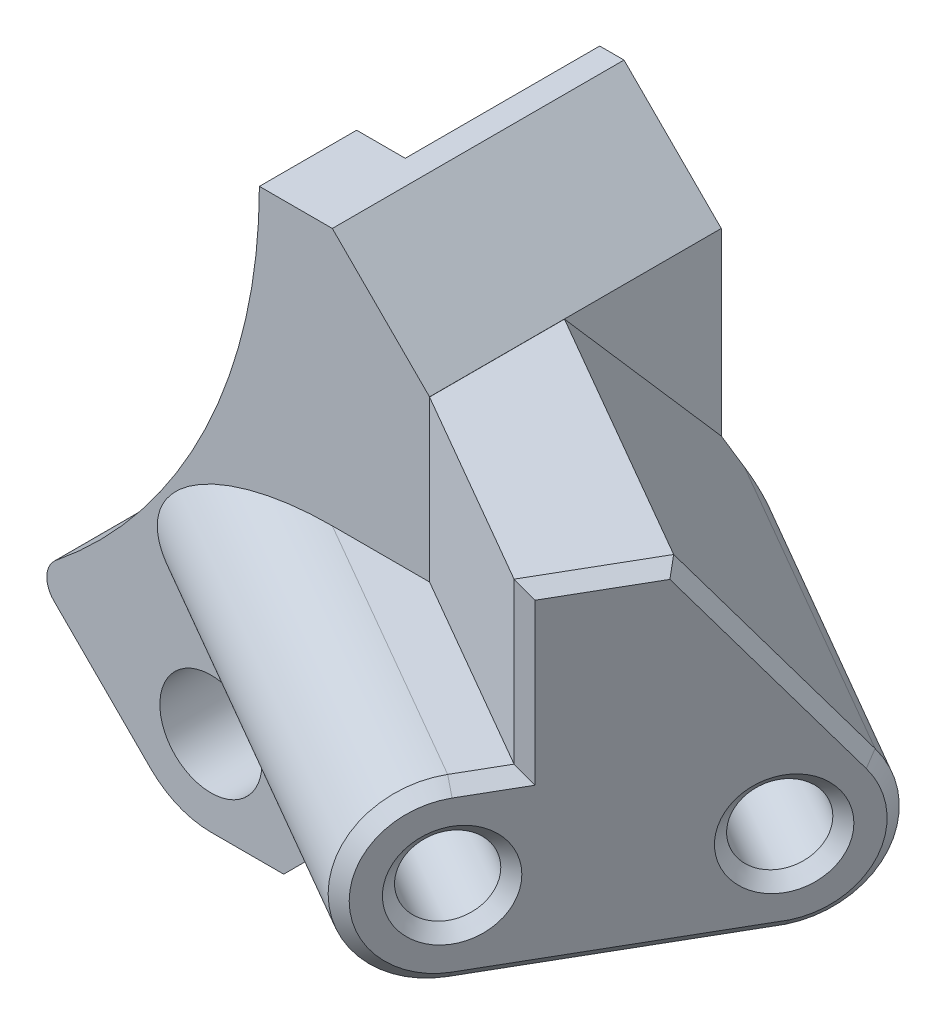
from build123d import *

# Parameters (mm, degrees)
SKETCH1_R           = 2.100000000000001
BOSS_EXTRUDE1_DEPTH = 12
BOSS_EXTRUDE2_START = -6.21
BOSS_EXTRUDE2_DEPTH = 13.79
CUT_EXTRUDE1_DEPTH  = 8
BOSS_EXTRUDE3_REACH = 41.051
SKETCH4_R           = 1.6
SKETCH4_R_2         = 1.6000000000000019
CUT_EXTRUDE2_DEPTH  = 40.05068839257359
CHAMFER2_SIZE       = 4
CUT_EXTRUDE3_REACH  = 41.051
CHAMFER3_SIZE       = 6
CUT_EXTRUDE4_START  = -12.5
CUT_EXTRUDE4_DEPTH  = 27.550688504002913
FILLET1_R           = 1
CHAMFER4_SIZE       = 0.5
FILLET2_R           = 3


with BuildPart() as part:
    # Sketch1 → Boss-Extrude1 (new body)
    with BuildSketch(Plane.XY):
        with BuildLine():
            Line((13.241359911348773, -18.191107379654646), (18.031222920256923, -22.980970388562806))
            ThreePointArc((18.031222920256923, -22.980970388562806), (19.166704641132032, -23.73967501819941), (20.50609665440986, -24.006096654409898))
            Line((20.50609665440986, -24.006096654409898), (29.499999999999993, -24.006096654409898))
            Line((29.499999999999993, -24.006096654409898), (29.499999999999993, 3.7e-16))
            Line((29.499999999999993, 3.7e-16), (22.500000000000007, 1.32e-15))
            ThreePointArc((22.500000000000007, 1.32e-15), (20.052189381777588, -10.205866009179541), (13.241359911348773, -18.191107379654646))
        make_face()
        with Locations((20.506096654409866, -20.5060966544099)):
            Circle(SKETCH1_R, mode=Mode.SUBTRACT)
    extrude(amount=BOSS_EXTRUDE1_DEPTH)

    # Sketch2 → Boss-Extrude2 (add)
    with BuildSketch(Plane.XZ.offset(24.006096654409898).offset(BOSS_EXTRUDE2_START)):
        Polygon((36.42820323027541, 1.1e-16), (29.499999999999993, 0), (29.499999999999993, 12), (38.1602540378444, 16.99999999999995), (45.08845726811982, 4.999999999999951), align=None)
    extrude(amount=-BOSS_EXTRUDE2_DEPTH)

    # Sketch3 → Cut-Extrude1 (cut)
    with BuildSketch(Plane(origin=(0, 0, 0), x_dir=(-1, 0, 0), z_dir=(0, 0, -1))):
        with BuildLine():
            Line((-18.031222920256923, -22.980970388562806), (-14.671554465329313, -19.621301933635188))
            ThreePointArc((-14.671554465329313, -19.621301933635188), (17.324116139070405, 17.324116139070437), (-19.621301933635156, -14.671554465329354))
            Line((-19.621301933635156, -14.671554465329354), (-22.98097038856278, -18.031222920256983))
            ThreePointArc((-22.98097038856278, -18.031222920256983), (-23.739675018199375, -19.1667046411321), (-24.00609665440987, -20.506096654409927))
            Line((-24.00609665440987, -20.506096654409927), (-24.00609665440987, -24.0060966544099))
            Line((-24.00609665440987, -24.0060966544099), (-20.50609665440986, -24.006096654409905))
            ThreePointArc((-20.50609665440986, -24.006096654409905), (-19.166704641132036, -23.739675018199403), (-18.031222920256923, -22.980970388562806))
        make_face()
    extrude(amount=-CUT_EXTRUDE1_DEPTH, mode=Mode.SUBTRACT)

    # Boss-Extrude3: up to this plane
    boss_extrude3_end = Plane(origin=(0, 0, 12), z_dir=(0, 0, 1))
    # Sketch5 → Boss-Extrude3 (add, up to the surface)
    with BuildSketch(Plane(origin=(35.98140646055117, 0, 20.77387470582027), x_dir=(0.4999999999999946, 0, -0.8660254037844417), z_dir=(0.8660254037844417, 0, 0.4999999999999946)), mode=Mode.PRIVATE) as boss_extrude3_sk1:
        with BuildLine():
            Line((2.357695154586543, -10.5960966544099), (4.357695154586543, -10.5960966544099))
            Line((4.357695154586543, -10.5960966544099), (4.357695154586545, -17.796096654409897))
            Line((4.357695154586545, -17.796096654409897), (2.3576951545865437, -17.796096654409897))
            ThreePointArc((2.3576951545865437, -17.796096654409897), (-1.2423048454134564, -14.1960966544099), (2.357695154586543, -10.5960966544099))
        make_face()
    boss_extrude3_tool1 = split(extrude(boss_extrude3_sk1.sketch, amount=-BOSS_EXTRUDE3_REACH, mode=Mode.PRIVATE), bisect_by=boss_extrude3_end, keep=Keep.BOTH, mode=Mode.PRIVATE)
    add(boss_extrude3_tool1.solids().sort_by_distance((36.919961, -14.196097, 19.148251))[0])

    # Sketch4 → Cut-Extrude2 (cut, through all)
    with BuildSketch(Plane(origin=(35.98140646055118, 0, 20.773874705820273), x_dir=(0.49999999999999495, 0, -0.8660254037844417), z_dir=(0.8660254037844417, 0, 0.49999999999999495))):
        with Locations((2.357695154586536, -14.2)):
            Circle(SKETCH4_R)
        with Locations((12.357695154586537, -14.2)):
            Circle(SKETCH4_R_2)
    extrude(amount=-CUT_EXTRUDE2_DEPTH, mode=Mode.SUBTRACT)

    # Chamfer2
    chamfer2_edges = [part.edges().sort_by_distance(p)[0] for p in [
        (29.499999999999993, 3.7e-16, 6),
    ]]
    chamfer(chamfer2_edges, length=CHAMFER2_SIZE)

    # Cut-Extrude3: up to this plane
    cut_extrude3_end = Plane(origin=(29.499999999999993, -24.006096654409898, 12), z_dir=(-1, 0, 0))
    # Sketch7 → Cut-Extrude3 (cut, up to the surface)
    with BuildSketch(Plane(origin=(35.98140646055117, 0, 20.77387470582027), x_dir=(0.4999999999999946, 0, -0.8660254037844417), z_dir=(0.8660254037844417, 0, 0.4999999999999946)), mode=Mode.PRIVATE) as cut_extrude3_sk1:
        with BuildLine():
            Line((15.22937626137959, -12.028952413951306), (9.16393898536506, -4.0060966544099))
            Line((9.16393898536506, -4.0060966544099), (22.041886428240783, -4.0060966544099))
            Line((22.041886428240783, -4.0060966544099), (22.041886428240783, -24.0060966544099))
            Line((22.041886428240783, -24.0060966544099), (2.357695154586543, -24.006096654409905))
            Line((2.357695154586543, -24.006096654409905), (2.357695154586542, -17.796096654409897))
            Line((2.357695154586542, -17.796096654409897), (12.357695154586544, -17.8))
            ThreePointArc((12.357695154586544, -17.8), (15.580719457145811, -15.803781264734175), (15.22937626137959, -12.028952413951306))
        make_face()
    cut_extrude3_tool1 = split(extrude(cut_extrude3_sk1.sketch, amount=-CUT_EXTRUDE3_REACH, mode=Mode.PRIVATE), bisect_by=cut_extrude3_end, keep=Keep.BOTH, mode=Mode.PRIVATE)
    add(cut_extrude3_tool1.solids().sort_by_distance((42.191658, -7.848292, 10.017403))[0], mode=Mode.SUBTRACT)

    # Chamfer3
    chamfer3_edges = [part.edges().sort_by_distance(p)[0] for p in [
        (29.499999999999993, -24.006096654409898, 6),
    ]]
    chamfer(chamfer3_edges, length=CHAMFER3_SIZE)

    # Sketch8 → Cut-Extrude4 (cut, through all)
    with BuildSketch(Plane(origin=(35.98140646055117, 0, 20.77387470582027), x_dir=(0.4999999999999946, 0, -0.8660254037844417), z_dir=(0.8660254037844417, 0, 0.4999999999999946)).offset(CUT_EXTRUDE4_START)):
        Polygon((5.257695154586542, -15.874315780649912), (5.257695154586541, -12.525684219350083), (2.3576951545865397, -10.85136843870017), (-0.5423048454134567, -12.525684219350083), (-0.5423048454134562, -15.874315780649912), (2.3576951545865446, -17.54863156129983), align=None)
        Polygon((9.457695154586544, -12.525684219350088), (9.457695154586544, -15.874315780649908), (12.35769515458654, -17.54863156129982), (15.257695154586537, -15.874315780649905), (15.257695154586537, -12.525684219350087), (12.357695154586539, -10.851368438700176), align=None)
    extrude(amount=-CUT_EXTRUDE4_DEPTH, mode=Mode.SUBTRACT)

    # Fillet1
    fillet1_edges = [part.edges().sort_by_distance(p)[0] for p in [
        (13.241359911348777, -18.191107379654646, 10),
        (24.00609665440987, -23.50000000000002, 4),
    ]]
    fillet(fillet1_edges, radius=FILLET1_R)

    # Chamfer4
    chamfer4_edges = [part.edges().sort_by_distance(p)[0] for p in [
        (36.36025403784444, -14.2, 20.11769145362395),
        (41.36025403784439, -14.2, 11.457437415779536),
        (39.70215336073716, -17.796096654409897, 14.329352032593636),
        (35.36025403784445, -14.1960966544099, 21.849742261192826),
        (37.660254037844425, -10.5960966544099, 17.866025403784395),
        (38.1602540378444, -7.3010966544099, 16.99999999999995),
        (39.36181499553902, -4.006096654409898, 14.918835372881723),
        (42.079735272237265, -8.017524534180602, 10.211259362718662),
        (43.790000296334796, -15.728302500078335, 7.2489934465736905),
    ]]
    chamfer(chamfer4_edges, length=CHAMFER4_SIZE)

    # Fillet2
    fillet2_edges = [part.edges().sort_by_distance(p)[0] for p in [
        (19.621301933635156, -14.671554465329354, 2.8324293970035703),
    ]]
    fillet(fillet2_edges, radius=FILLET2_R)


solid = part.part
